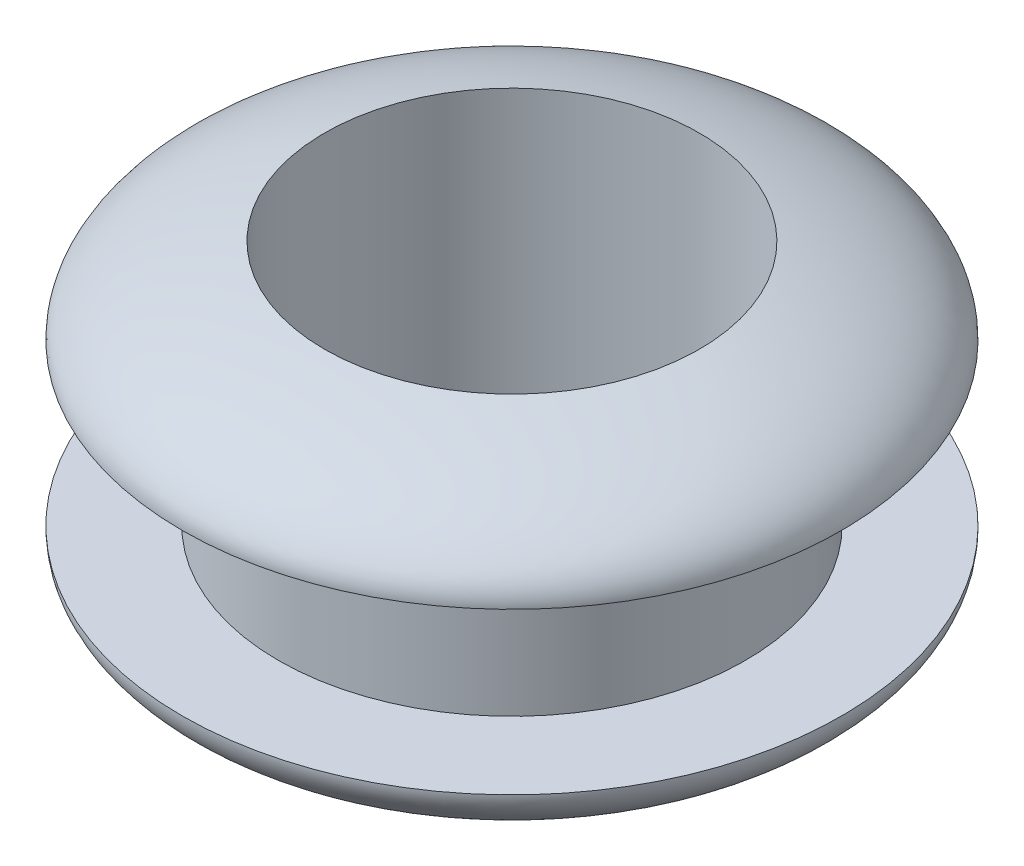
from build123d import *

# Parameters (mm, degrees)
SKETCH_2_R          = 3.5
CUT_EXTRUDE_1_DEPTH = 9.0000001


with BuildPart() as part:
    # 草图1 → 旋转1 (revolve)
    with BuildSketch(Plane(origin=(0, 0, 0), x_dir=(0, 0, -1), z_dir=(1, 0, 0))):
        with BuildLine():
            Line((4.36, -1.5), (6.155493681, -1.5))
            add(Edge.make_bspline(
                [(0, -3.5), (6.193222519, -3.387724216), (6.155493681, -1.5)],
                knots=[4.706296987, 4.706296987, 4.706296987, 6.283185307, 6.283185307, 6.283185307], degree=2, weights=[1, 0.704949659, 1]))
            Line((0, -3.5), (0, 3.5))
            add(Edge.make_bspline(
                [(6.155493681, 1.5), (6.193222519, 3.387724216), (0, 3.5)],
                knots=[0, 0, 0, 1.57688832, 1.57688832, 1.57688832], degree=2, weights=[1, 0.704949659, 1]))
            Line((6.155493681, 1.5), (4.36, 1.5))
            Line((4.36, 1.5), (4.36, -1.5))
        make_face()
    revolve(axis=Axis((0, 6.516349088, 0), (0, -1, 0)))

    # 草图2 → 切除-拉伸1 (cut, through all)
    with BuildSketch(Plane(origin=(0, 4.5, 0), x_dir=(1, 0, 0), z_dir=(0, 1, 0))):
        Circle(SKETCH_2_R)
    extrude(amount=-CUT_EXTRUDE_1_DEPTH, mode=Mode.SUBTRACT)


solid = part.part
